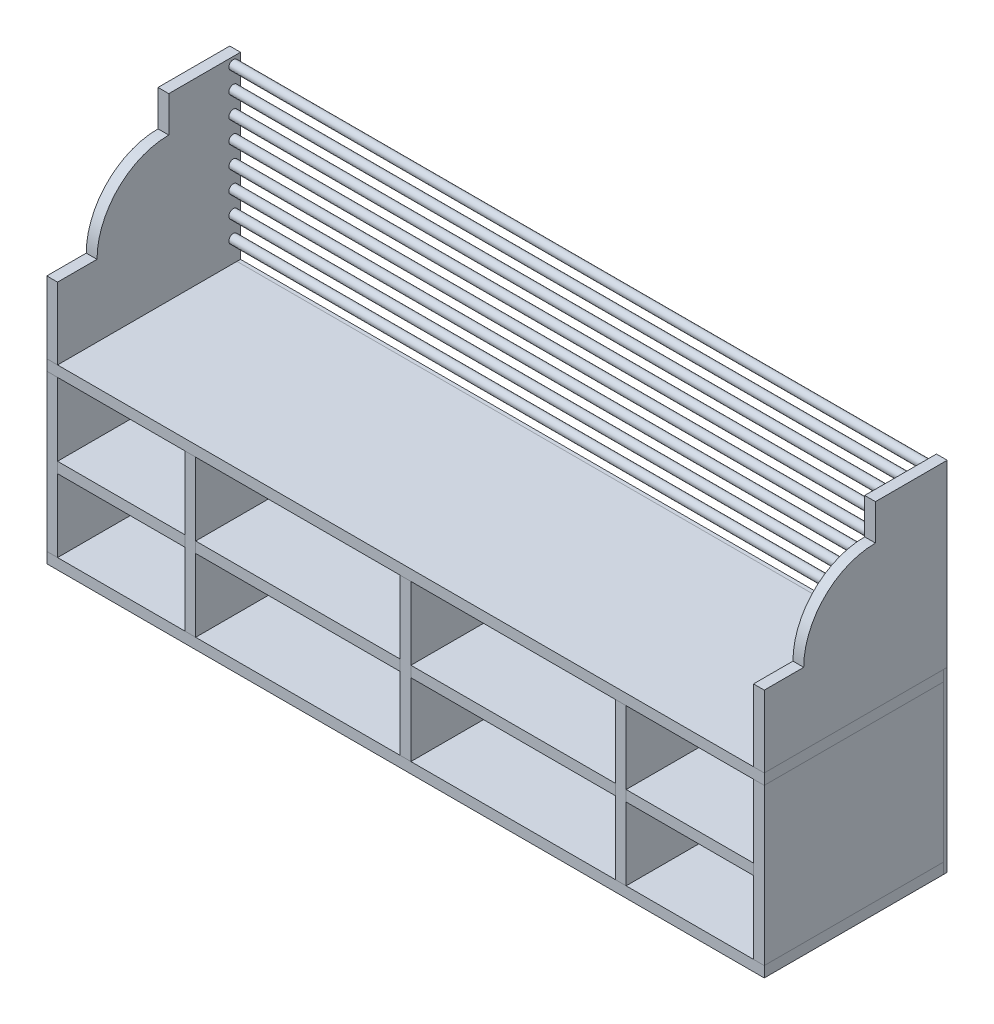
from build123d import *

# Parameters (mm, degrees)
SKETCH1_W             = 2000
SKETCH1_H             = 30
BOSS_EXTRUDE1_DEPTH   = 250
SKETCH3_W             = 30
SKETCH3_H             = 435
BOSS_EXTRUDE3_DEPTH   = 500
BOSS_EXTRUDE3_2_DEPTH = 500
BOSS_EXTRUDE3_3_DEPTH = 500
BOSS_EXTRUDE3_4_DEPTH = 500
BOSS_EXTRUDE3_5_DEPTH = 500
SKETCH6_W             = 355
SKETCH6_H             = 30
BOSS_EXTRUDE6_DEPTH   = 500
SKETCH6_W_2           = 570
BOSS_EXTRUDE6_2_DEPTH = 500
BOSS_EXTRUDE6_3_DEPTH = 500
BOSS_EXTRUDE6_4_DEPTH = 500
SKETCH7_W             = 2000
SKETCH7_H             = 495
BOSS_EXTRUDE7_DEPTH   = 10
BOSS_EXTRUDE8_DEPTH   = 30
SKETCH11_R            = 12.5
BOSS_EXTRUDE10_DEPTH  = 1970


with BuildPart() as part:
    # Sketch1 → Boss-Extrude1 (new body, symmetric)
    with BuildSketch(Plane.XY):
        Rectangle(SKETCH1_W, SKETCH1_H)
    extrude(amount=BOSS_EXTRUDE1_DEPTH, both=True)


with BuildPart() as body_2:
    # Body-Move/Copy1: copy of part
    add(part.part.moved(Location((0, 465, 0))))


with BuildPart() as body_3:
    # Sketch3 → Boss-Extrude3 (new body)
    with BuildSketch(Plane.XY.offset(250)):
        with Locations((-985, 232.5)):
            Rectangle(SKETCH3_W, SKETCH3_H)
    extrude(amount=-BOSS_EXTRUDE3_DEPTH)


with BuildPart() as body_4:
    # Sketch3 → Boss-Extrude3 2 (new body)
    with BuildSketch(Plane.XY.offset(250)):
        with Locations((-600, 232.5)):
            Rectangle(SKETCH3_W, SKETCH3_H)
    extrude(amount=-BOSS_EXTRUDE3_2_DEPTH)


with BuildPart() as body_5:
    # Sketch3 → Boss-Extrude3 3 (new body)
    with BuildSketch(Plane.XY.offset(250)):
        with Locations((0, 232.5)):
            Rectangle(SKETCH3_W, SKETCH3_H)
    extrude(amount=-BOSS_EXTRUDE3_3_DEPTH)


with BuildPart() as body_6:
    # Sketch3 → Boss-Extrude3 4 (new body)
    with BuildSketch(Plane.XY.offset(250)):
        with Locations((600, 232.5)):
            Rectangle(SKETCH3_W, SKETCH3_H)
    extrude(amount=-BOSS_EXTRUDE3_4_DEPTH)


with BuildPart() as body_7:
    # Sketch3 → Boss-Extrude3 5 (new body)
    with BuildSketch(Plane.XY.offset(250)):
        with Locations((985, 232.5)):
            Rectangle(SKETCH3_W, SKETCH3_H)
    extrude(amount=-BOSS_EXTRUDE3_5_DEPTH)


with BuildPart() as body_8:
    # Sketch6 → Boss-Extrude6 (new body)
    with BuildSketch(Plane.XY.offset(250)):
        with Locations((-792.5, 232.5)):
            Rectangle(SKETCH6_W, SKETCH6_H)
    extrude(amount=-BOSS_EXTRUDE6_DEPTH)


with BuildPart() as body_9:
    # Sketch6 → Boss-Extrude6 2 (new body)
    with BuildSketch(Plane.XY.offset(250)):
        with Locations((-300, 232.5)):
            Rectangle(SKETCH6_W_2, SKETCH6_H)
    extrude(amount=-BOSS_EXTRUDE6_2_DEPTH)


with BuildPart() as body_10:
    # Sketch6 → Boss-Extrude6 3 (new body)
    with BuildSketch(Plane.XY.offset(250)):
        with Locations((300, 232.5)):
            Rectangle(SKETCH6_W_2, SKETCH6_H)
    extrude(amount=-BOSS_EXTRUDE6_3_DEPTH)


with BuildPart() as body_11:
    # Sketch6 → Boss-Extrude6 4 (new body)
    with BuildSketch(Plane.XY.offset(250)):
        with Locations((792.5, 232.5)):
            Rectangle(SKETCH6_W, SKETCH6_H)
    extrude(amount=-BOSS_EXTRUDE6_4_DEPTH)


with BuildPart() as body_12:
    # Sketch7 → Boss-Extrude7 (new body)
    with BuildSketch(Plane(origin=(0, 0, -250), x_dir=(-1, 0, 0), z_dir=(0, 0, -1))):
        with Locations((0, 232.5)):
            Rectangle(SKETCH7_W, SKETCH7_H)
    extrude(amount=BOSS_EXTRUDE7_DEPTH)


with BuildPart() as body_13:
    # Sketch8 → Boss-Extrude8 (new body)
    with BuildSketch(Plane(origin=(1000, 0, 0), x_dir=(0, 0, -1), z_dir=(1, 0, 0))):
        with BuildLine():
            Line((-250, 480), (-250, 680))
            Line((-250, 680), (-140, 680))
            ThreePointArc((-140, 680), (-81.421356237, 821.421356237), (60, 880))
            Line((60, 880), (60, 980))
            Line((60, 980), (260, 980))
            Line((260, 980), (260, 480))
            Line((260, 480), (-250, 480))
        make_face()
    extrude(amount=-BOSS_EXTRUDE8_DEPTH)


with BuildPart() as body_14:
    # Body-Move/Copy2: copy of body 13
    add(body_13.part.moved(Location((-1970, 0, 0))))


with BuildPart() as body_13_1:
    add(body_13.part)

    add(body_14.part)  # Boss-Extrude10 merges body 14
    # Sketch11 → Boss-Extrude10 (add)
    with BuildSketch(Plane.ZY.offset(-970)):
        with Locations((-240, 960)):
            Circle(SKETCH11_R)
        with Locations((-240, 900)):
            Circle(SKETCH11_R)
        with Locations((-240, 840)):
            Circle(SKETCH11_R)
        with Locations((-240, 780)):
            Circle(SKETCH11_R)
        with Locations((-240, 720)):
            Circle(SKETCH11_R)
        with Locations((-240, 660)):
            Circle(SKETCH11_R)
        with Locations((-240, 600)):
            Circle(SKETCH11_R)
        with Locations((-240, 540)):
            Circle(SKETCH11_R)
    extrude(amount=BOSS_EXTRUDE10_DEPTH)


solid = Compound([part.part, body_2.part, body_3.part, body_4.part, body_5.part, body_6.part, body_7.part, body_8.part, body_9.part, body_10.part, body_11.part, body_12.part, body_13_1.part])
